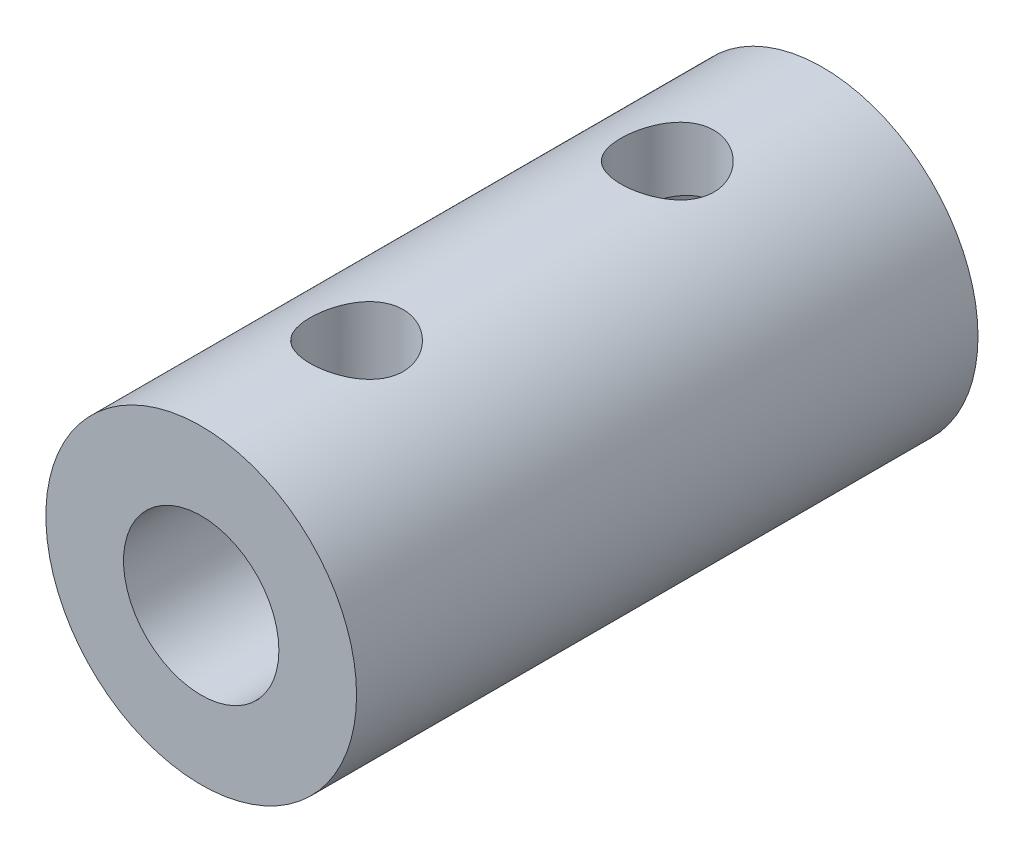
from build123d import *

# Parameters (mm, degrees)
SKETCH1_R           = 5
SKETCH1_R_2         = 3
BOSS_EXTRUDE1_DEPTH = 10
SKETCH2_R           = 5
SKETCH2_R_2         = 2.5
BOSS_EXTRUDE2_DEPTH = 10
SKETCH3_R           = 1.5
CUT_EXTRUDE1_DEPTH  = 10


with BuildPart() as part:
    # Sketch1 → Boss-Extrude1 (new body)
    with BuildSketch(Plane.XY):
        Circle(SKETCH1_R)
        Circle(SKETCH1_R_2, mode=Mode.SUBTRACT)
    extrude(amount=BOSS_EXTRUDE1_DEPTH)

    # Sketch2 → Boss-Extrude2 (add)
    with BuildSketch(Plane.XY.offset(10)):
        Circle(SKETCH2_R)
        Circle(SKETCH2_R_2, mode=Mode.SUBTRACT)
    extrude(amount=BOSS_EXTRUDE2_DEPTH)

    # Sketch3 → Cut-Extrude1 (cut)
    with BuildSketch(Plane(origin=(0, 0, 0), x_dir=(1, 0, 0), z_dir=(0, 1, 0))):
        with Locations((0, -5)):
            Circle(SKETCH3_R)
        with Locations((0, -15)):
            Circle(SKETCH3_R)
    extrude(amount=CUT_EXTRUDE1_DEPTH, mode=Mode.SUBTRACT)


solid = part.part
